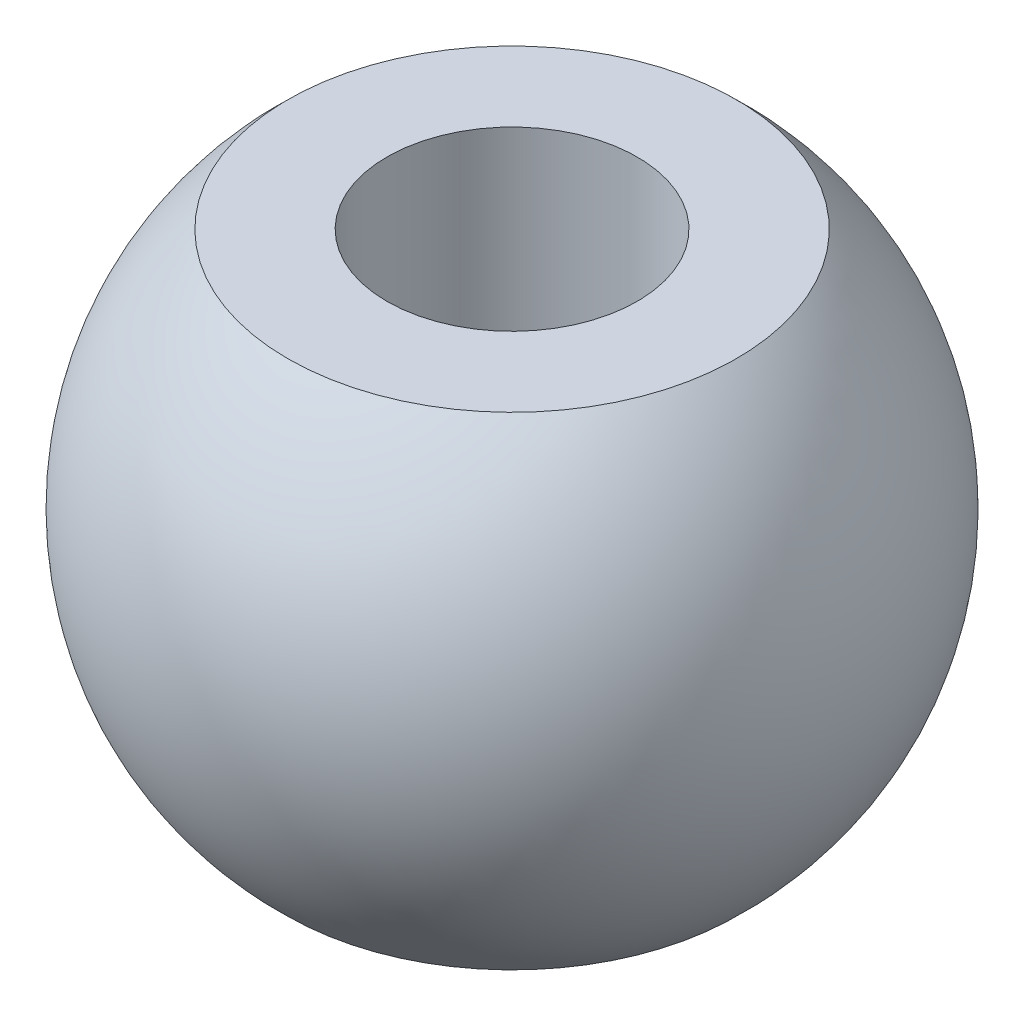
from build123d import *

# Parameters (mm, degrees)
SKETCH_5_R          = 4.675
CUT_EXTRUDE_3_DEPTH = 1.25
SKETCH_6_R          = 1.775
CUT_EXTRUDE_4_DEPTH = 9.1


with BuildPart() as part:
    # 스케치4 → 회전2 (revolve)
    with BuildSketch(Plane(origin=(0, 0, 0), x_dir=(1, 0, 0), z_dir=(0, 1, 0))):
        with BuildLine():
            Line((0, 4.675), (0, -4.675))
            ThreePointArc((0, -4.675), (4.675, 0), (0, 4.675))
        make_face()
    revolve(axis=Axis((0, 0, -5.538954721), (0, 0, 1)))

    # 스케치5 → 컷-돌출3 (cut)
    with BuildSketch(Plane(origin=(0, 4.675, 0), x_dir=(1, 0, 0), z_dir=(0, 1, 0))):
        Circle(SKETCH_5_R)
    cut_extrude_3 = extrude(amount=-CUT_EXTRUDE_3_DEPTH, mode=Mode.SUBTRACT)

    # 대칭 복사2: 컷-돌출3 across plane
    add(cut_extrude_3.mirror(Plane.ZX), mode=Mode.SUBTRACT)

    # 스케치6 → 컷-돌출4 (cut, through all)
    with BuildSketch(Plane(origin=(0, 3.425, 0), x_dir=(1, 0, 0), z_dir=(0, 1, 0))):
        Circle(SKETCH_6_R)
    extrude(amount=-CUT_EXTRUDE_4_DEPTH, mode=Mode.SUBTRACT)


solid = part.part
